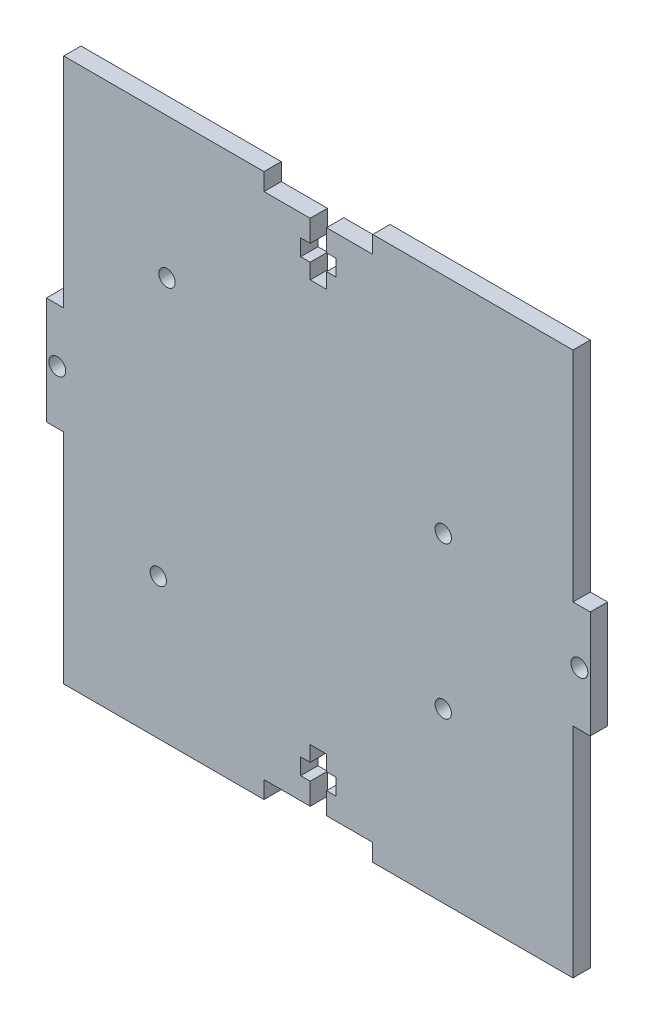
from build123d import *

# Parameters (mm, degrees)
SKETCH1_W           = 100
SKETCH1_H           = 100
BOSS_EXTRUDE2_DEPTH = 3.18
SKETCH2_R           = 1.55
SKETCH2_W           = 3.18
SKETCH2_H           = 40.125
CUT_EXTRUDE1_DEPTH  = 4.18
SKETCH3_R           = 1.5
CUT_EXTRUDE2_DEPTH  = 4.18


with BuildPart() as part:
    # Sketch1 → Boss-Extrude2 (new body)
    with BuildSketch(Plane.XY):
        Rectangle(SKETCH1_W, SKETCH1_H)
    extrude(amount=BOSS_EXTRUDE2_DEPTH)

    # Sketch2 → Cut-Extrude1 (cut, through all)
    with BuildSketch(Plane.XY.offset(3.18)):
        with Locations((-48, 0)):
            Circle(SKETCH2_R)
        Polygon((-10, 50), (-10, 46.82), (-1.5, 46.82), (-1.5, 42.82), (-3.25, 42.82), (-3.25, 39.82), (-1.5, 39.82), (-1.5, 37), (1.5, 37), (1.5, 39.82), (3.25, 39.82), (3.25, 42.82), (1.5, 42.82), (1.5, 46.82), (10, 46.82), (10, 50), align=None)
        with Locations((-48.41, 29.9375)):
            Rectangle(SKETCH2_W, SKETCH2_H)
        with Locations((-48.41, -29.9375)):
            Rectangle(SKETCH2_W, SKETCH2_H)
    cut_extrude1 = extrude(amount=-CUT_EXTRUDE1_DEPTH, mode=Mode.SUBTRACT)

    # Mirror1: Cut-Extrude1 across plane
    add(cut_extrude1.mirror(Plane.ZX), mode=Mode.SUBTRACT)

    # Mirror3: Cut-Extrude1 across plane
    add(cut_extrude1.mirror(Plane(origin=(0, 0, 0), x_dir=(0, 0, 1), z_dir=(1, 0, 0))), mode=Mode.SUBTRACT)

    # Sketch3 → Cut-Extrude2 (cut, through all)
    with BuildSketch(Plane(origin=(0, 0, 0), x_dir=(-1, 0, 0), z_dir=(0, 0, -1))):
        with Locations((27.832447704, 24.15)):
            Circle(SKETCH3_R)
        with Locations((29.432447704, -24.15)):
            Circle(SKETCH3_R)
        with Locations((-22.967552296, -19.05)):
            Circle(SKETCH3_R)
        with Locations((-22.967552296, 8.85)):
            Circle(SKETCH3_R)
    extrude(amount=-CUT_EXTRUDE2_DEPTH, mode=Mode.SUBTRACT)


solid = part.part
